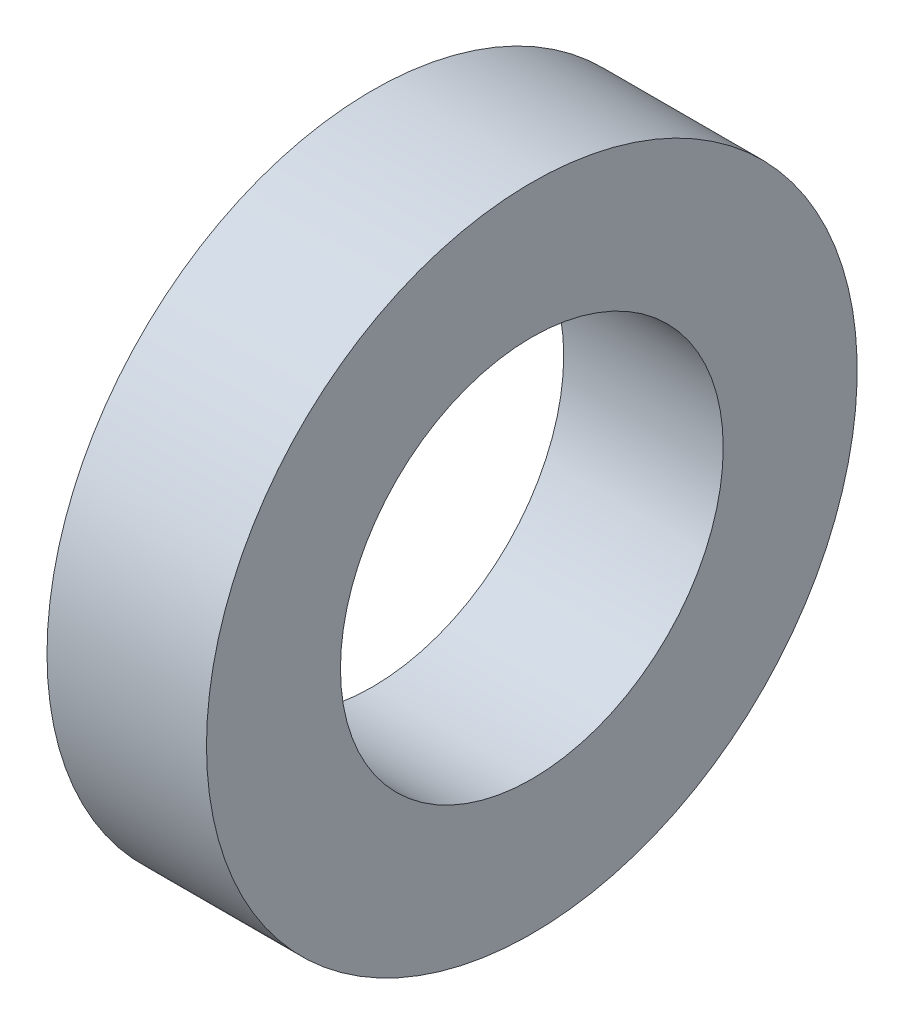
from build123d import *

# Parameters (mm, degrees)
ESBO_O1_W = 7.9375
ESBO_O1_H = 6.6675


with BuildPart() as part:
    # Esboço1 → Revolução1 (revolve)
    with BuildSketch(Plane.XY):
        with Locations((-3.96875, 12.85875)):
            Rectangle(ESBO_O1_W, ESBO_O1_H)
    revolve(axis=Axis((0, 0, 0), (-1, 0, 0)))


solid = part.part
